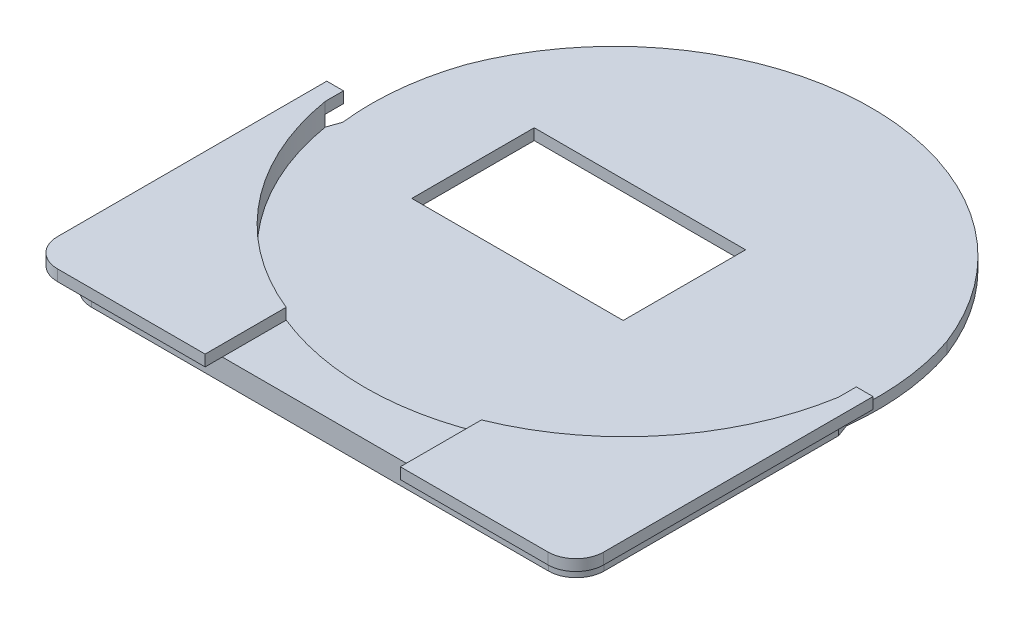
from build123d import *

# Parameters (mm, degrees)
BOSS_EXTRUDE2_DEPTH = 4
CUT_EXTRUDE3_DEPTH  = 4
SKETCH6_R           = 46.644893749
CUT_EXTRUDE4_DEPTH  = 2
SKETCH7_W           = 37.921763703
SKETCH7_H           = 21.966033547
CUT_EXTRUDE5_DEPTH  = 2
CUT_EXTRUDE7_DEPTH  = 10
BOSS_EXTRUDE3_DEPTH = 2


with BuildPart() as part:
    # Sketch4 → Boss-Extrude2 (new body)
    with BuildSketch(Plane(origin=(0, 0, 0), x_dir=(1, 0, 0), z_dir=(0, 1, 0))):
        with BuildLine():
            Line((-107.035735829, 49.14195745), (-15.035735829, 49.14195745))
            Line((-15.035735829, 49.14195745), (-15.035735829, -45.85804255))
            ThreePointArc((-15.035735829, -45.85804255), (-16.500201924, -49.393576456), (-20.035735829, -50.85804255))
            Line((-20.035735829, -50.85804255), (-102.035735829, -50.85804255))
            ThreePointArc((-102.035735829, -50.85804255), (-105.571269735, -49.393576456), (-107.035735829, -45.85804255))
            Line((-107.035735829, -45.85804255), (-107.035735829, 49.14195745))
        make_face()
    extrude(amount=BOSS_EXTRUDE2_DEPTH)

    # Sketch5 → Cut-Extrude3 (cut)
    with BuildSketch(Plane(origin=(0, 4, 0), x_dir=(1, 0, 0), z_dir=(0, 1, 0))):
        with BuildLine():
            Line((-122.184107688, 54.312207558), (-0.881081782, 54.312207558))
            Line((-0.881081782, 54.312207558), (-0.881081782, -1.763818638))
            Line((-0.881081782, -1.763818638), (-15.035735829, -1.763818638))
            ThreePointArc((-15.035735829, -1.763818638), (-61.035735829, 48.088703252), (-107.035735829, -1.763818638))
            Line((-107.035735829, -1.763818638), (-116.20594022, -1.763818638))
            Line((-116.20594022, -1.763818638), (-122.184107688, 54.312207558))
        make_face()
    extrude(amount=-CUT_EXTRUDE3_DEPTH, mode=Mode.SUBTRACT)

    # Sketch6 → Cut-Extrude4 (cut)
    with BuildSketch(Plane(origin=(0, 4, 0), x_dir=(1, 0, 0), z_dir=(0, 1, 0))):
        with Locations((-61.039241489, 3.84195745)):
            Circle(SKETCH6_R)
    extrude(amount=-CUT_EXTRUDE4_DEPTH, mode=Mode.SUBTRACT)

    # Sketch7 → Cut-Extrude5 (cut)
    with BuildSketch(Plane(origin=(0, 2, 0), x_dir=(1, 0, 0), z_dir=(0, 1, 0))):
        with Locations((-69.228954178, 3.760987583)):
            Rectangle(SKETCH7_W, SKETCH7_H)
    extrude(amount=-CUT_EXTRUDE5_DEPTH, mode=Mode.SUBTRACT)

    # Sketch13 → Cut-Extrude7 (cut)
    with BuildSketch(Plane(origin=(0, 2, 0), x_dir=(1, 0, 0), z_dir=(0, 1, 0))):
        with BuildLine():
            Line((-106.217317024, -1.560957592), (-107.035735829, -3.908437462))
            Line((-107.035735829, -3.908437462), (-110.118060938, -1.560957592))
            ThreePointArc((-110.118060938, -1.560957592), (-61.039241489, 53.217275266), (-11.960422041, -1.560957592))
            Line((-11.960422041, -1.560957592), (-15.035735829, -3.816260145))
            Line((-15.035735829, -3.816260145), (-15.861165954, -1.560957592))
            ThreePointArc((-15.861165954, -1.560957592), (-61.039241489, 49.34195745), (-106.217317024, -1.560957592))
        make_face()
    extrude(amount=-CUT_EXTRUDE7_DEPTH, mode=Mode.SUBTRACT)

    # Sketch10 → Boss-Extrude3 (add)
    with BuildSketch(Plane(origin=(0, 4, 0), x_dir=(1, 0, 0), z_dir=(0, 1, 0))):
        with BuildLine():
            Line((-110.035735829, -0.626443871), (-107.035735829, -0.626443871))
            Line((-107.035735829, -0.626443871), (-107.035735829, -3.908437462))
            ThreePointArc((-107.035735829, -3.908437462), (-97.412251623, -25.359930275), (-78.547707812, -39.392284997))
            Line((-78.547707812, -39.392284997), (-78.547707812, -53.939312876))
            Line((-78.547707812, -53.939312876), (-105.035735829, -53.939312876))
            ThreePointArc((-105.035735829, -53.939312876), (-108.571269735, -52.474846782), (-110.035735829, -48.939312876))
            Line((-110.035735829, -48.939312876), (-110.035735829, -0.626443871))
        make_face()
        with BuildLine():
            Line((-12.035735829, -0.626443871), (-12.035735829, -48.939312876))
            ThreePointArc((-12.035735829, -48.939312876), (-13.500201924, -52.474846782), (-17.035735829, -53.939312876))
            Line((-17.035735829, -53.939312876), (-43.530775166, -53.939312876))
            Line((-43.530775166, -53.939312876), (-43.530775166, -39.392284997))
            ThreePointArc((-43.530775166, -39.392284997), (-24.652990845, -25.343430622), (-15.035735829, -3.86671169))
            Line((-15.035735829, -3.86671169), (-15.035735829, -0.626443871))
            Line((-15.035735829, -0.626443871), (-12.035735829, -0.626443871))
        make_face()
    extrude(amount=BOSS_EXTRUDE3_DEPTH)


solid = part.part
